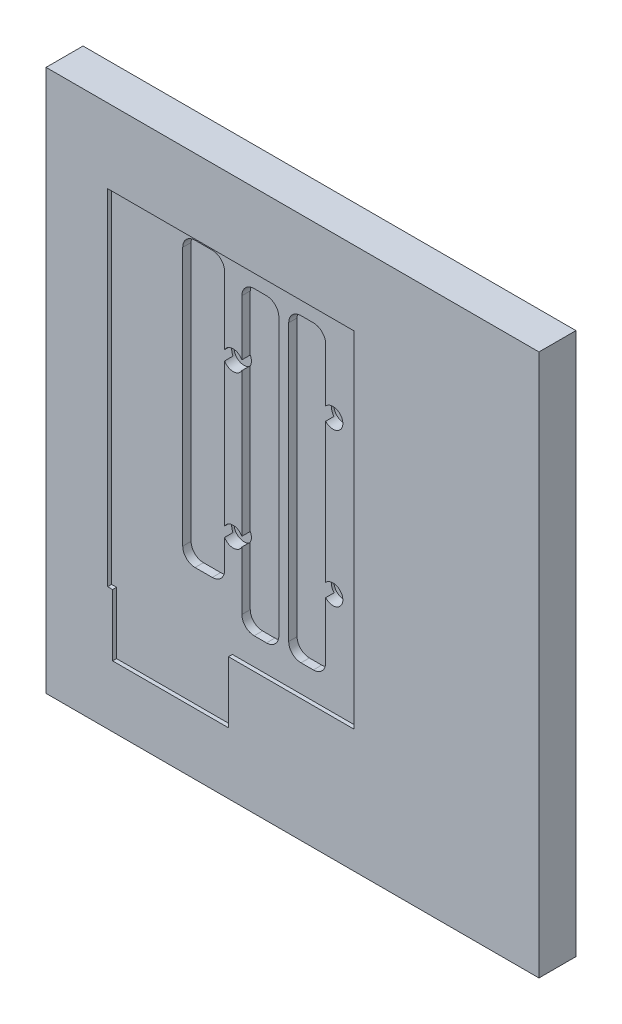
from build123d import *

# Parameters (mm, degrees)
ESQUISSE1_W             = 200
ESQUISSE1_H             = 220
BOSS_EXTRU_1_DEPTH      = 15
ESQUISSE2_R             = 4
ENL_V_MAT_EXTRU_1_DEPTH = 6
ENL_V_MAT_EXTRU_2_DEPTH = 1.6
ENL_V_MAT_EXTRU_3_DEPTH = 5


with BuildPart() as part:
    # Esquisse1 → Boss.-Extru.1 (new body)
    with BuildSketch(Plane.XY):
        with Locations((100, 110)):
            Rectangle(ESQUISSE1_W, ESQUISSE1_H)
    extrude(amount=BOSS_EXTRU_1_DEPTH)

    # Esquisse2 → Enlèv. mat.-Extru.1 (cut)
    with BuildSketch(Plane.XY.offset(15)):
        with Locations((74.322, 91.45)):
            Circle(ESQUISSE2_R)
        with Locations((74.322, 153.45)):
            Circle(ESQUISSE2_R)
        with Locations((114.822, 91.45)):
            Circle(ESQUISSE2_R)
        with Locations((114.822, 153.45)):
            Circle(ESQUISSE2_R)
    extrude(amount=-ENL_V_MAT_EXTRU_1_DEPTH, mode=Mode.SUBTRACT)

    # Esquisse3 → Enlèv. mat.-Extru.2 (cut)
    with BuildSketch(Plane.XY.offset(15)):
        Polygon((27, 50), (27, 24.928776057), (74, 24.928776057), (74, 49.915697098), (124.85, 49.915697098), (124.85, 189.875697098), (25, 189.875697098), (25, 50), align=None)
    extrude(amount=-ENL_V_MAT_EXTRU_2_DEPTH, mode=Mode.SUBTRACT)

    # Esquisse4 → Enlèv. mat.-Extru.3 (cut)
    with BuildSketch(Plane.XY.offset(15)):
        with BuildLine():
            Line((106.85, 182.875697098), (101.85, 182.875697098))
            ThreePointArc((101.85, 182.875697098), (98.314466094, 181.411231003), (96.85, 177.875697098))
            Line((96.85, 177.875697098), (96.85, 65.875697098))
            ThreePointArc((96.85, 65.875697098), (98.314466094, 62.340163192), (101.85, 60.875697098))
            Line((101.85, 60.875697098), (106.85, 60.875697098))
            ThreePointArc((106.85, 60.875697098), (110.385533906, 62.340163192), (111.85, 65.875697098))
            Line((111.85, 65.875697098), (111.85, 177.875697098))
            ThreePointArc((111.85, 177.875697098), (110.385533906, 181.411231003), (106.85, 182.875697098))
        make_face()
        with BuildLine():
            Line((87.85, 60.875697098), (82.85, 60.875697098))
            ThreePointArc((82.85, 60.875697098), (79.314466094, 62.340163192), (77.85, 65.875697098))
            Line((77.85, 65.875697098), (77.85, 177.875697098))
            ThreePointArc((77.85, 177.875697098), (79.314466094, 181.411231003), (82.85, 182.875697098))
            Line((82.85, 182.875697098), (87.85, 182.875697098))
            ThreePointArc((87.85, 182.875697098), (91.385533906, 181.411231003), (92.85, 177.875697098))
            Line((92.85, 177.875697098), (92.85, 65.875697098))
            ThreePointArc((92.85, 65.875697098), (91.385533906, 62.340163192), (87.85, 60.875697098))
        make_face()
        with BuildLine():
            Line((65.85, 187.875697098), (58.85, 187.875697098))
            ThreePointArc((58.85, 187.875697098), (55.314466094, 186.411231003), (53.85, 182.875697098))
            Line((53.85, 182.875697098), (53.85, 77.875697098))
            ThreePointArc((53.85, 77.875697098), (55.314466094, 74.340163192), (58.85, 72.875697098))
            Line((58.85, 72.875697098), (65.85, 72.875697098))
            ThreePointArc((65.85, 72.875697098), (69.385533906, 74.340163192), (70.85, 77.875697098))
            Line((70.85, 77.875697098), (70.85, 182.875697098))
            ThreePointArc((70.85, 182.875697098), (69.385533906, 186.411231003), (65.85, 187.875697098))
        make_face()
    extrude(amount=-ENL_V_MAT_EXTRU_3_DEPTH, mode=Mode.SUBTRACT)


solid = part.part
